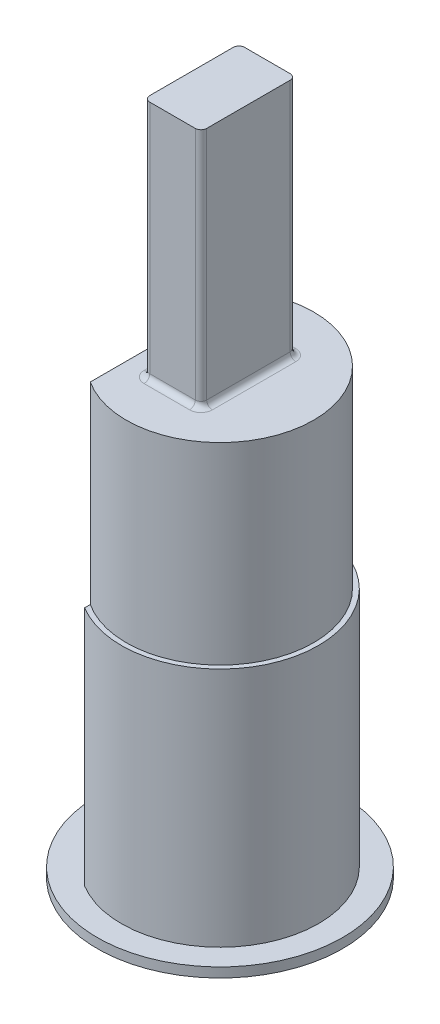
from build123d import *

# Parameters (mm, degrees)
BOSS_EXTRUDE1_DEPTH = 22.86
BOSS_EXTRUDE2_DEPTH = 12.7
FILLET1_R           = 0.3
SKETCH3_R           = 6.46557
BOSS_EXTRUDE3_DEPTH = 0.508
SKETCH4_OUTSIDE_W   = 23.02
SKETCH4_OUTSIDE_H   = 23.02
SKETCH4_OUTSIDE_R   = 4.94157
CUT_EXTRUDE1_DEPTH  = 10.16


with BuildPart() as part:
    # Sketch1 → Boss-Extrude1 (new body)
    with BuildSketch(Plane(origin=(0, 0, 0), x_dir=(1, 0, 0), z_dir=(0, 1, 0))):
        with BuildLine():
            Line((-2.68996703, 4.445), (-2.68996703, -4.445))
            ThreePointArc((-2.68996703, -4.445), (5.19557, 0), (-2.68996703, 4.445))
        make_face()
    extrude(amount=BOSS_EXTRUDE1_DEPTH)

    # Sketch2 → Boss-Extrude2 (add)
    with BuildSketch(Plane(origin=(0, 22.86, 0), x_dir=(1, 0, 0), z_dir=(0, 1, 0))):
        with BuildLine():
            Line((-1.2, -2.5), (1.2, -2.5))
            ThreePointArc((1.2, -2.5), (1.412132034, -2.412132034), (1.5, -2.2))
            Line((1.5, -2.2), (1.5, 2.2))
            ThreePointArc((1.5, 2.2), (1.412132034, 2.412132034), (1.2, 2.5))
            Line((1.2, 2.5), (-1.2, 2.5))
            ThreePointArc((-1.2, 2.5), (-1.412132034, 2.412132034), (-1.5, 2.2))
            Line((-1.5, 2.2), (-1.5, -2.2))
            ThreePointArc((-1.5, -2.2), (-1.412132034, -2.412132034), (-1.2, -2.5))
        make_face()
    extrude(amount=BOSS_EXTRUDE2_DEPTH)

    # Fillet1
    fillet1_edges = [part.edges().sort_by_distance(p)[0] for p in [
        (-1.412132034, 22.86, 2.412132034),
        (0, 22.86, 2.5),
        (1.412132034, 22.86, 2.412132034),
        (1.5, 22.86, 0),
        (1.412132034, 22.86, -2.412132034),
        (0, 22.86, -2.5),
        (-1.412132034, 22.86, -2.412132034),
        (-1.5, 22.86, 0),
    ]]
    fillet(fillet1_edges, radius=FILLET1_R)

    # Sketch3 → Boss-Extrude3 (add)
    with BuildSketch(Plane.XZ):
        Circle(SKETCH3_R)
    extrude(amount=BOSS_EXTRUDE3_DEPTH)

    # Sketch4 outside → Cut-Extrude1 (cut)
    with BuildSketch(Plane(origin=(0, 22.86, 0), x_dir=(1, 0, 0), z_dir=(0, 1, 0))):
        Rectangle(SKETCH4_OUTSIDE_W, SKETCH4_OUTSIDE_H)
        Circle(SKETCH4_OUTSIDE_R, mode=Mode.SUBTRACT)
    extrude(amount=-CUT_EXTRUDE1_DEPTH, mode=Mode.SUBTRACT)


solid = part.part
